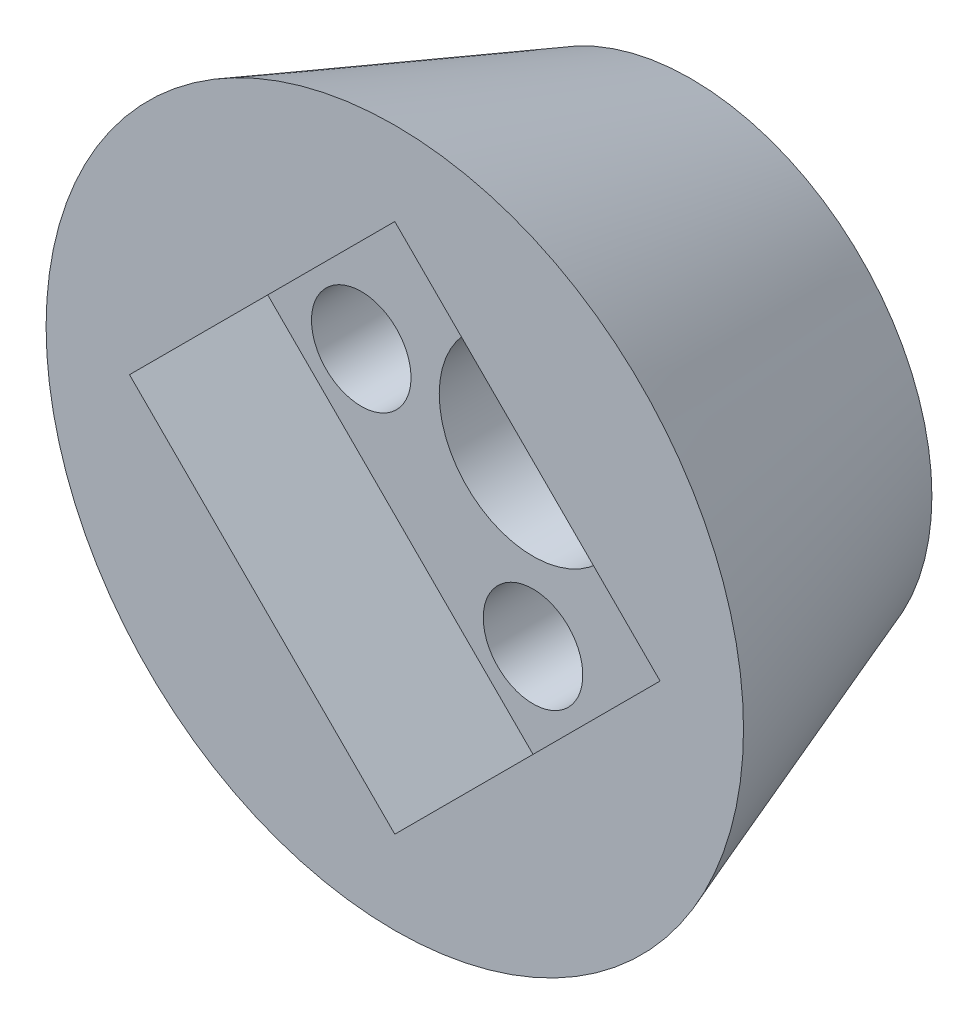
from build123d import *

# Parameters (mm, degrees)
GEARFACEPROFILE_R           = 12.2
GEARFACEEXTRUDE_DEPTH       = 15
GEARFACEEXTRUDE_TAPER       = -20
CENTERHOLEPROFILE_R         = 4.75
CENTERHOLECUT_DEPTH         = 16.0000001
SCREWHOLEPROFILE_R          = 2.52
SCREWHOLECUT_DEPTH          = 16.0000001
SHAFTCOLLARDOCKINGCUT_DEPTH = 7


with BuildPart() as part:
    # GearFaceProfile → GearFaceExtrude (new body)
    with BuildSketch(Plane.XY):
        Circle(GEARFACEPROFILE_R)
    extrude(amount=GEARFACEEXTRUDE_DEPTH, taper=GEARFACEEXTRUDE_TAPER)

    # CenterHoleProfile → CenterHoleCut (cut, through all)
    with BuildSketch(Plane(origin=(0, 0, 0), x_dir=(-1, 0, 0), z_dir=(0, 0, -1))):
        Circle(CENTERHOLEPROFILE_R)
    extrude(amount=-CENTERHOLECUT_DEPTH, mode=Mode.SUBTRACT)

    # ScrewHoleProfile → ScrewHoleCut (cut, through all)
    with BuildSketch(Plane(origin=(0, 0, 0), x_dir=(-1, 0, 0), z_dir=(0, 0, -1))):
        with Locations((0, 8.7)):
            Circle(SCREWHOLEPROFILE_R)
        with Locations((8.7, 0)):
            Circle(SCREWHOLEPROFILE_R)
        with Locations((0, -8.7)):
            Circle(SCREWHOLEPROFILE_R)
        with Locations((-8.7, 0)):
            Circle(SCREWHOLEPROFILE_R)
    extrude(amount=-SCREWHOLECUT_DEPTH, mode=Mode.SUBTRACT)

    # ShaftCollarAttachmentProfile → ShaftCollarDockingCut (cut)
    with BuildSketch(Plane.XY.offset(15)):
        Polygon((0, 13.435028843), (13.435028843, 0), (0, -13.435028843), (-13.435028843, 0), align=None)
    extrude(amount=-SHAFTCOLLARDOCKINGCUT_DEPTH, mode=Mode.SUBTRACT)


solid = part.part
